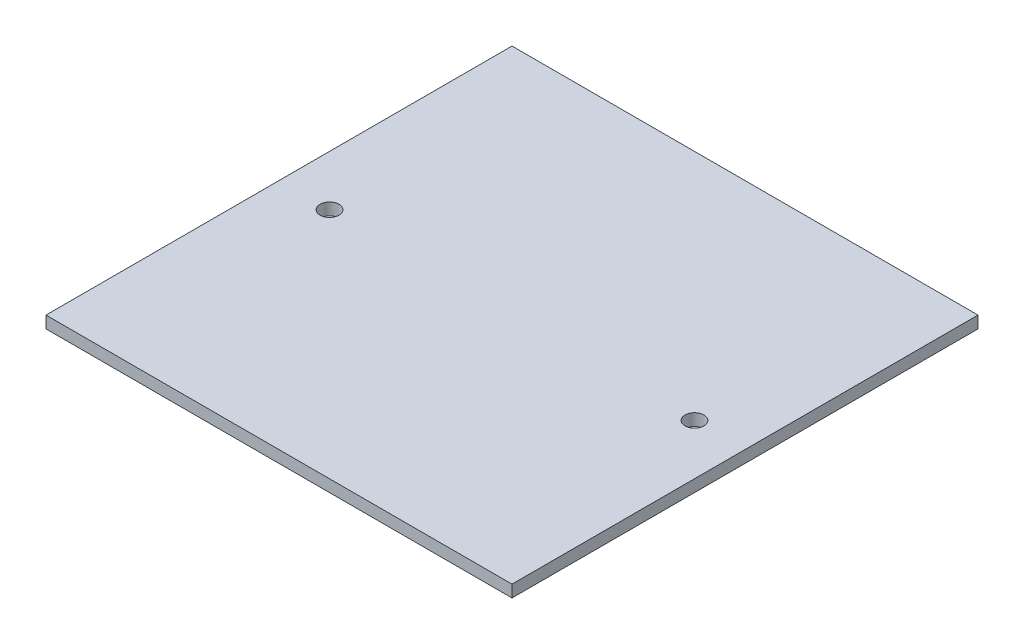
from build123d import *

# Parameters (mm, degrees)
CROQUIS1_W                 = 73.8
CROQUIS1_H                 = 73.8
SALIENTE_EXTRUIR3_DEPTH    = 1.9
CROQUIS2_R                 = 1.5
CORTAR_EXTRUIR1_DEPTH      = 1
CORTAR_EXTRUIR1_DEPTH_BACK = 2.9


with BuildPart() as part:
    # Croquis1 → Saliente-Extruir3 (new body)
    with BuildSketch(Plane(origin=(0, 0, 0), x_dir=(1, 0, 0), z_dir=(0, 1, 0))):
        Rectangle(CROQUIS1_W, CROQUIS1_H)
    extrude(amount=SALIENTE_EXTRUIR3_DEPTH)

    # Croquis2 → Cortar-Extruir1 (cut, two sides)
    with BuildSketch(Plane(origin=(0, 1.9, 0), x_dir=(1, 0, 0), z_dir=(0, 1, 0))) as cortar_extruir1_sk:
        with Locations((-28.9, 0)):
            Circle(CROQUIS2_R)
        with Locations((28.9, 0)):
            Circle(CROQUIS2_R)
    extrude(amount=CORTAR_EXTRUIR1_DEPTH, mode=Mode.SUBTRACT)
    extrude(cortar_extruir1_sk.sketch, amount=-CORTAR_EXTRUIR1_DEPTH_BACK, mode=Mode.SUBTRACT)


solid = part.part
